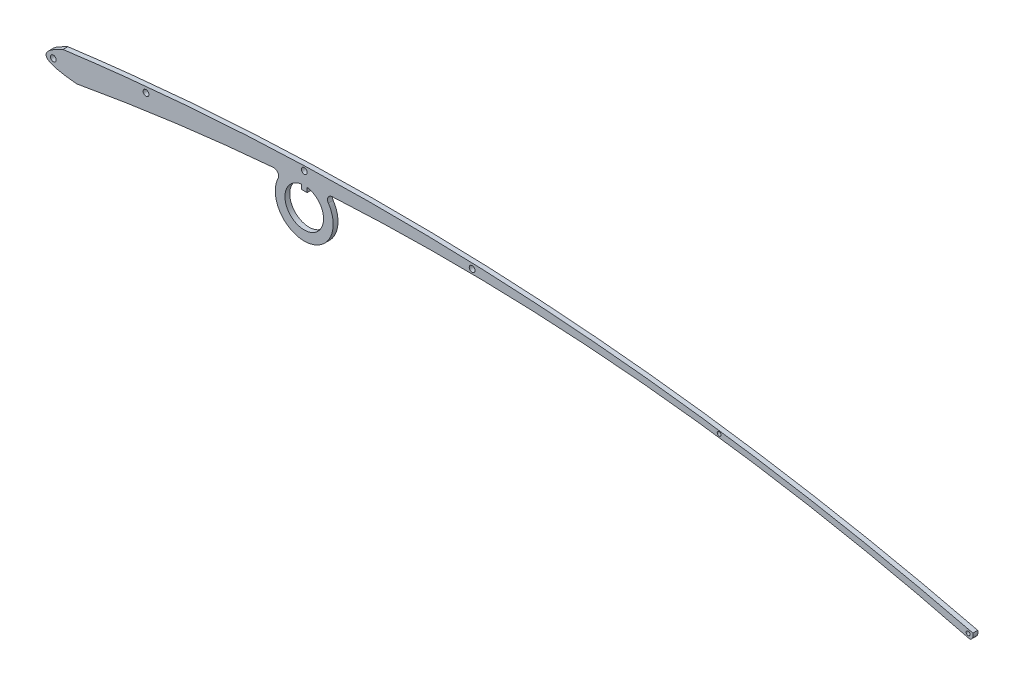
from build123d import *

# Parameters (mm, degrees)
EXTRUDE_1_DEPTH     = 0.25
SKETCH_3_R          = 0.3
SKETCH_3_R_2        = 0.2
CUT_EXTRUDE_1_DEPTH = 0.25
EXTRUDE_2_DEPTH     = 0.25
FILLET_1_R          = 0.5


with BuildPart() as part:
    # 草图2 → 凸台-拉伸1 (new, symmetric)
    with BuildSketch(Plane.XY):
        with BuildLine():
            ThreePointArc((94.3, -5.23), (94.279085645, -5.63954323), (94, -5.94))
            add(Edge.make_bspline(
                [(1.4, -2.38), (47.954561827, 5.976867864), (94, -5.94)],
                knots=[0, 0, 0, 1, 1, 1], degree=2))
            add(Edge.make_bspline(
                [(0, 0), (-4.123736473, -1.859487618), (1.4, -2.38)],
                knots=[0, 0, 0, 1, 1, 1], degree=2))
            add(Edge.make_bspline(
                [(0, 0), (47.273266317, 6.255778848), (94.3, -5.23)],
                knots=[0, 0, 0, 1, 1, 1], degree=2))
        make_face()
    extrude(amount=EXTRUDE_1_DEPTH, both=True)

    # 草图3 → 切除-拉伸1 (cut, symmetric)
    with BuildSketch(Plane.XY):
        with Locations((-1, -1.3)):
            Circle(SKETCH_3_R)
        with Locations((8.6, 0.4)):
            Circle(SKETCH_3_R)
        with Locations((25, 1.6)):
            Circle(SKETCH_3_R)
        with Locations((42.4, 1.5)):
            Circle(SKETCH_3_R)
        with Locations((68, -0.5)):
            Circle(SKETCH_3_R_2)
        with Locations((93.8, -5.5)):
            Circle(SKETCH_3_R_2)
    extrude(amount=CUT_EXTRUDE_1_DEPTH, both=True, mode=Mode.SUBTRACT)

    # 草图4 → 凸台-拉伸2 (add, symmetric)
    with BuildSketch(Plane.XY):
        with BuildLine():
            ThreePointArc((22.854587938, 0.396951856), (25.20918356, -4.692698154), (26.83283005, 0.675022949))
            add(Edge.make_bspline(
                [(22.854587938, 0.396951856), (24.844176287, 0.554595418), (26.83283005, 0.675022949)],
                knots=[0, 0, 0, 1, 1, 1], degree=2))
        make_face()
        with BuildLine():
            Line((24.7, 0.277371993), (24.7, -0.2))
            Line((24.7, -0.2), (25.3, -0.2))
            Line((25.3, -0.2), (25.3, 0.277371993))
            ThreePointArc((25.3, 0.277371993), (25, -3.7), (24.7, 0.277371993))
        make_face(mode=Mode.SUBTRACT)
    extrude(amount=EXTRUDE_2_DEPTH, both=True)

    # 圆角1
    fillet_1_edges = [part.edges().sort_by_distance(p)[0] for p in [
        (26.83283005, 0.675022949, -0.125),
        (22.854587938, 0.396951856, -0.125),
    ]]
    fillet(fillet_1_edges, radius=FILLET_1_R)


solid = part.part
